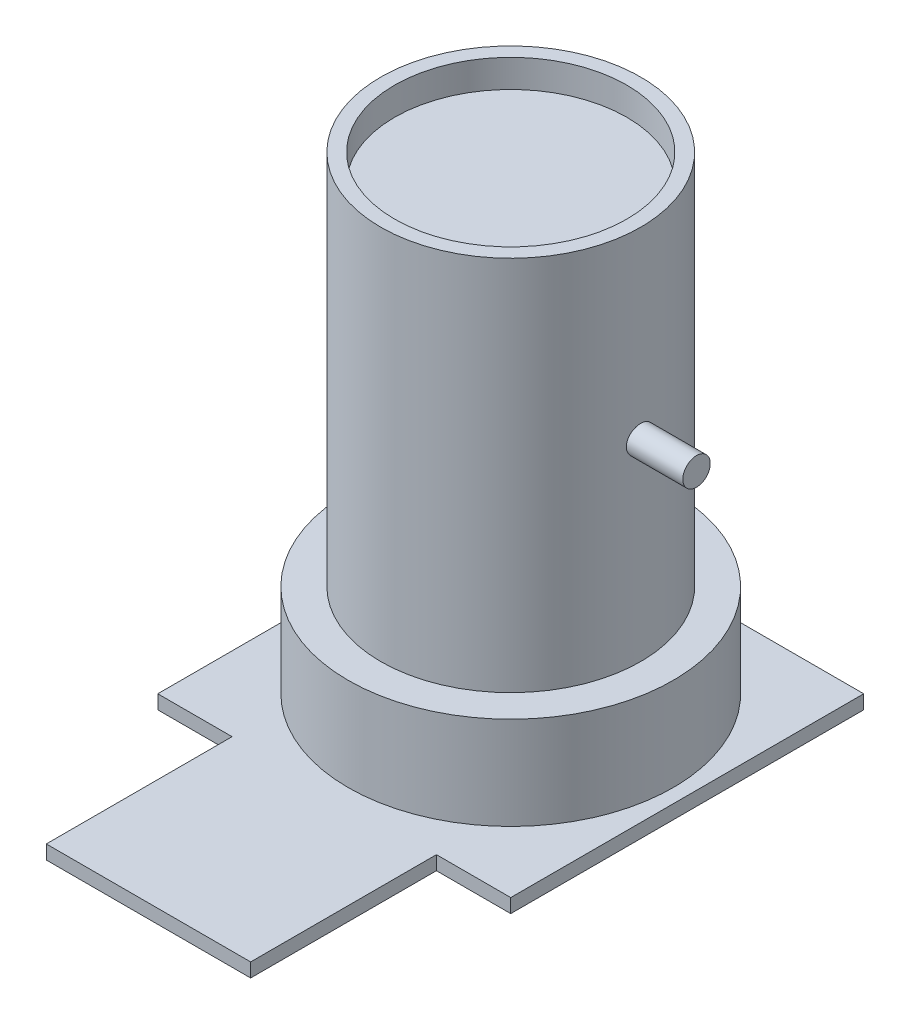
from build123d import *

# Parameters (mm, degrees)
SKETCH1_W           = 38
SKETCH1_H           = 38
BOSS_EXTRUDE1_DEPTH = 1.5
SKETCH2_R           = 17.5
BOSS_EXTRUDE2_DEPTH = 10
SKETCH3_R           = 14
BOSS_EXTRUDE3_DEPTH = 40.5
SKETCH4_R           = 12.5
CUT_EXTRUDE1_DEPTH  = 3
SKETCH5_R           = 1.478595514
BOSS_EXTRUDE4_DEPTH = 20
SKETCH6_W           = 22
SKETCH6_H           = 1.5
BOSS_EXTRUDE5_DEPTH = 20


with BuildPart() as part:
    # Sketch1 → Boss-Extrude1 (new body)
    with BuildSketch(Plane(origin=(0, 0, 0), x_dir=(1, 0, 0), z_dir=(0, 1, 0))):
        Rectangle(SKETCH1_W, SKETCH1_H)
    extrude(amount=BOSS_EXTRUDE1_DEPTH)

    # Sketch2 → Boss-Extrude2 (add)
    with BuildSketch(Plane(origin=(0, 1.5, 0), x_dir=(1, 0, 0), z_dir=(0, 1, 0))):
        Circle(SKETCH2_R)
    extrude(amount=BOSS_EXTRUDE2_DEPTH)

    # Sketch3 → Boss-Extrude3 (add)
    with BuildSketch(Plane(origin=(0, 11.5, 0), x_dir=(1, 0, 0), z_dir=(0, 1, 0))):
        Circle(SKETCH3_R)
    extrude(amount=BOSS_EXTRUDE3_DEPTH)

    # Sketch4 → Cut-Extrude1 (cut)
    with BuildSketch(Plane(origin=(0, 52, 0), x_dir=(1, 0, 0), z_dir=(0, 1, 0))):
        Circle(SKETCH4_R)
    extrude(amount=-CUT_EXTRUDE1_DEPTH, mode=Mode.SUBTRACT)

    # Sketch5 → Boss-Extrude4 (add)
    with BuildSketch(Plane(origin=(0, 0, 0), x_dir=(0, 0, -1), z_dir=(1, 0, 0))):
        with Locations((0, 32.23)):
            Circle(SKETCH5_R)
    extrude(amount=BOSS_EXTRUDE4_DEPTH)

    # Sketch6 → Boss-Extrude5 (add)
    with BuildSketch(Plane.XY.offset(19)):
        with Locations((0, 0.75)):
            Rectangle(SKETCH6_W, SKETCH6_H)
    extrude(amount=BOSS_EXTRUDE5_DEPTH)


solid = part.part
